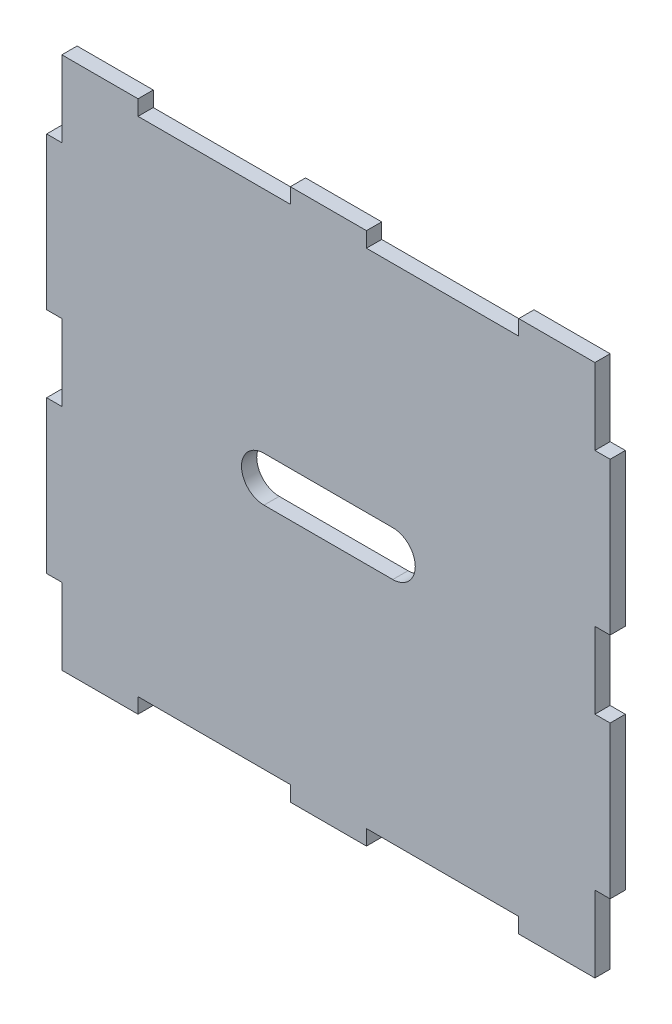
from build123d import *

# Parameters (mm, degrees)
SKETCH1_W           = 70
SKETCH1_H           = 70
BOSS_EXTRUDE1_DEPTH = 2
SKETCH2_W           = 2
SKETCH2_H           = 20
BOSS_EXTRUDE2_DEPTH = 2
SKETCH3_W           = 20
SKETCH3_H           = 2
CUT_EXTRUDE1_DEPTH  = 2
SKETCH4_W           = 16.92
SKETCH4_H           = 5.9
CUT_EXTRUDE2_DEPTH  = 10


with BuildPart() as part:
    # Sketch1 → Boss-Extrude1 (new body)
    with BuildSketch(Plane.XY):
        Rectangle(SKETCH1_W, SKETCH1_H)
    extrude(amount=-BOSS_EXTRUDE1_DEPTH)

    # Sketch2 → Boss-Extrude2 (add)
    with BuildSketch(Plane.XY):
        with Locations((-36, 15)):
            Rectangle(SKETCH2_W, SKETCH2_H)
        with Locations((-36, -15)):
            Rectangle(SKETCH2_W, SKETCH2_H)
        with Locations((36, -15)):
            Rectangle(SKETCH2_W, SKETCH2_H)
        with Locations((36, 15)):
            Rectangle(SKETCH2_W, SKETCH2_H)
    extrude(amount=-BOSS_EXTRUDE2_DEPTH)

    # Sketch3 → Cut-Extrude1 (cut)
    with BuildSketch(Plane.XY):
        with Locations((-15, 34)):
            Rectangle(SKETCH3_W, SKETCH3_H)
        with Locations((15, 34)):
            Rectangle(SKETCH3_W, SKETCH3_H)
        with Locations((-15, -34)):
            Rectangle(SKETCH3_W, SKETCH3_H)
        with Locations((15, -34)):
            Rectangle(SKETCH3_W, SKETCH3_H)
    extrude(amount=-CUT_EXTRUDE1_DEPTH, mode=Mode.SUBTRACT)

    # Sketch4 → Cut-Extrude2 (cut)
    with BuildSketch(Plane.XY):
        Rectangle(SKETCH4_W, SKETCH4_H)
        with BuildLine():
            ThreePointArc((8.46, 2.95), (11.41, 0), (8.46, -2.95))
            Line((8.46, -2.95), (8.46, 2.95))
        make_face()
        with BuildLine():
            Line((-8.46, -2.95), (-8.46, 2.95))
            ThreePointArc((-8.46, 2.95), (-11.41, 0), (-8.46, -2.95))
        make_face()
    extrude(amount=-CUT_EXTRUDE2_DEPTH, mode=Mode.SUBTRACT)


solid = part.part
